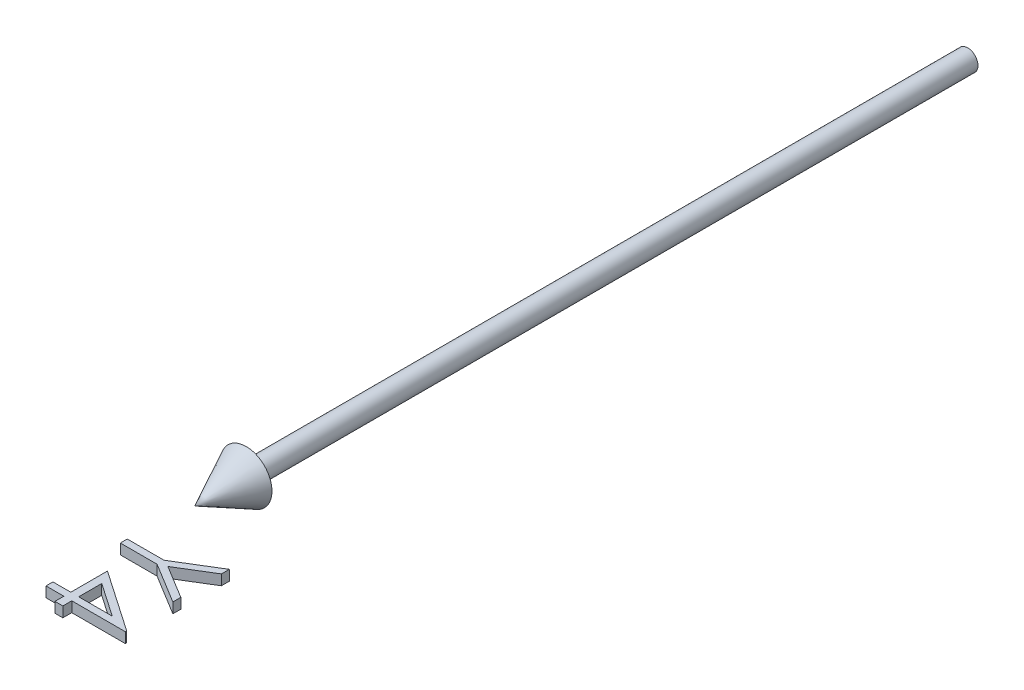
from build123d import *

# Parameters (mm, degrees)
BOSS_EXTRUDE1_DEPTH        = 1
BOSS_EXTRUDE1_DEPTH_BACK   = 1
BOSS_EXTRUDE1_2_DEPTH      = 1
BOSS_EXTRUDE1_2_DEPTH_BACK = 1


with BuildPart() as part:
    # Sketch2 → Revolve1 (revolve)
    with BuildSketch(Plane(origin=(0, 0, 0), x_dir=(1, 0, 0), z_dir=(0, 1, 0))):
        Polygon((0, -150), (5, -140), (2, -140), (2, 0), (0, 0), align=None)
    revolve(axis=Axis((0, 0, -41.949952025), (0, 0, 1)))


with BuildPart() as body_2:
    # Sketch3 → Boss-Extrude1 (new, two sides: drawn at the far end of the back side and taken through both)
    with BuildSketch(Plane(origin=(0, 0, 0), x_dir=(1, 0, 0), z_dir=(0, 1, 0)).offset(-BOSS_EXTRUDE1_DEPTH_BACK)):
        Polygon((15, -158.269230769), (15, -159.810697115), (8.5546875, -163.753004808), (15, -167.689302885), (15, -169.230769231), (7.130408654, -164.423076923), (0, -164.423076923), (0, -163.076923077), (7.130408654, -163.076923077), align=None)
    extrude(amount=BOSS_EXTRUDE1_DEPTH + BOSS_EXTRUDE1_DEPTH_BACK)


with BuildPart() as body_3:
    # Sketch3 → Boss-Extrude1 2 (new, two sides: drawn at the far end of the back side and taken through both)
    with BuildSketch(Plane(origin=(0, 0, 0), x_dir=(1, 0, 0), z_dir=(0, 1, 0)).offset(-BOSS_EXTRUDE1_2_DEPTH_BACK)):
        Polygon((15.384615385, -178.572716346), (15.384615385, -178.846153846), (5, -178.846153846), (5, -180.576923077), (3.461538462, -180.576923077), (3.461538462, -178.846153846), (0, -178.846153846), (0, -177.5), (3.461538462, -177.5), (3.461538462, -170.384615385), align=None)
        Polygon((5, -177.5), (11.514423077, -177.5), (5, -173.028846154), align=None, mode=Mode.SUBTRACT)
    extrude(amount=BOSS_EXTRUDE1_2_DEPTH + BOSS_EXTRUDE1_2_DEPTH_BACK)


solid = Compound([part.part, body_2.part, body_3.part])
